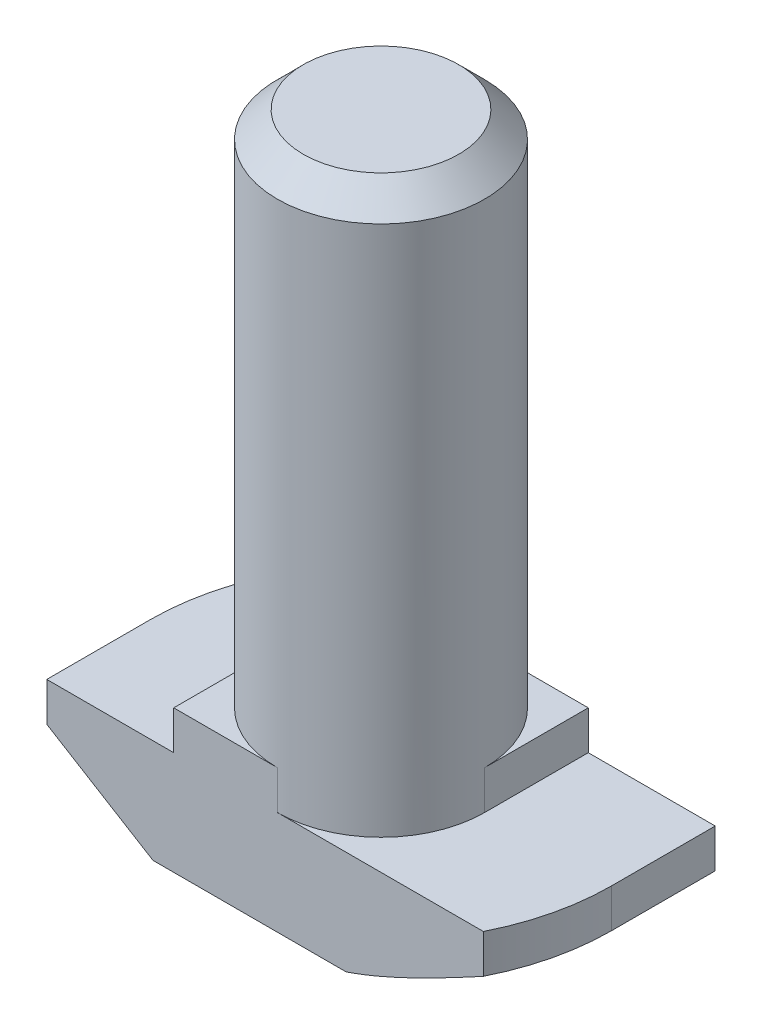
from build123d import *

# Parameters (mm, degrees)
EXTRUDE_1_DEPTH     = 4
CUT_EXTRUDE_1_DEPTH = 1.5
SKETCH_2_R          = 4
EXTRUDE_2_DEPTH     = 20
CUT_EXTRUDE_2_DEPTH = 5
CHAMFER_2_SIZE      = 1


with BuildPart() as part:
    # Эскиз1 → Бобышка-Вытянуть1 (new body, symmetric)
    with BuildSketch(Plane.XY):
        Polygon((8.9, 0), (-8.9, 0), (-8.9, 4), (-4, 4), (-4, 5.5), (4, 5.5), (4, 4), (8.9, 4), align=None)
    extrude(amount=EXTRUDE_1_DEPTH, both=True)

    # Эскиз3 → Вырез-Вытянуть1 (cut)
    with BuildSketch(Plane(origin=(0, 5.5, 0), x_dir=(1, 0, 0), z_dir=(0, 1, 0))):
        with BuildLine():
            Line((-4, 0), (-4, 4))
            Line((-4, 4), (0, 4))
            ThreePointArc((0, 4), (-2.828427125, 2.828427125), (-4, 0))
        make_face()
        with BuildLine():
            Line((0, -4), (4, -4))
            Line((4, -4), (4, 0))
            ThreePointArc((4, 0), (2.828427125, -2.828427125), (0, -4))
        make_face()
    extrude(amount=-CUT_EXTRUDE_1_DEPTH, mode=Mode.SUBTRACT)

    # Эскиз2 → Бобышка-Вытянуть2 (add)
    with BuildSketch(Plane(origin=(0, 5.5, 0), x_dir=(1, 0, 0), z_dir=(0, 1, 0))):
        with Locations(Location((0, 0, 0), (0, 0, 270))):  # turned: the seam where the file's is
            Circle(SKETCH_2_R)
    extrude(amount=EXTRUDE_2_DEPTH)

    # Эскиз4 → Вырез-Вытянуть2 (cut, through all)
    with BuildSketch(Plane(origin=(0, 4, 0), x_dir=(1, 0, 0), z_dir=(0, 1, 0))):
        with BuildLine():
            Line((-7.950471684, 4), (-8.9, 4))
            Line((-8.9, 4), (-8.9, 0))
            ThreePointArc((-8.9, 0), (-8.659364815, 2.055578022), (-7.950471684, 4))
        make_face()
        with BuildLine():
            Line((7.950471684, -4), (8.9, -4))
            Line((8.9, -4), (8.9, 0))
            ThreePointArc((8.9, 0), (8.659364815, -2.055578022), (7.950471684, -4))
        make_face()
    extrude(amount=-CUT_EXTRUDE_2_DEPTH, mode=Mode.SUBTRACT)

    # Вырез-По траектории1: sweep along a path in Эскиз6
    with BuildLine(Plane.XZ) as sweep_1_path:
        Line((0, -8.9), (8.9, -8.9))
        Line((8.9, -8.9), (8.9, 0))
        ThreePointArc((8.9, 0), (6.293250353, 6.293250353), (0, 8.9))
        Line((0, 8.9), (-8.9, 8.9))
        Line((-8.9, 8.9), (-8.9, 0))
        ThreePointArc((-8.9, 0), (-6.293250353, -6.293250353), (0, -8.9))
    # Эскиз5 → Вырез-По траектории1 (sweep, cut)
    with BuildSketch(Plane.XY.offset(4)):
        Polygon((-8.9, 2.5), (-4.8, 0), (-8.9, 0), align=None)
    sweep(path=sweep_1_path.line, transition=Transition.RIGHT, mode=Mode.SUBTRACT)

    # Фаска2
    chamfer_2_edges = [part.edges().sort_by_distance(p)[0] for p in [
        (0, 25.5, -4),
    ]]
    chamfer(chamfer_2_edges, length=CHAMFER_2_SIZE)


solid = part.part
